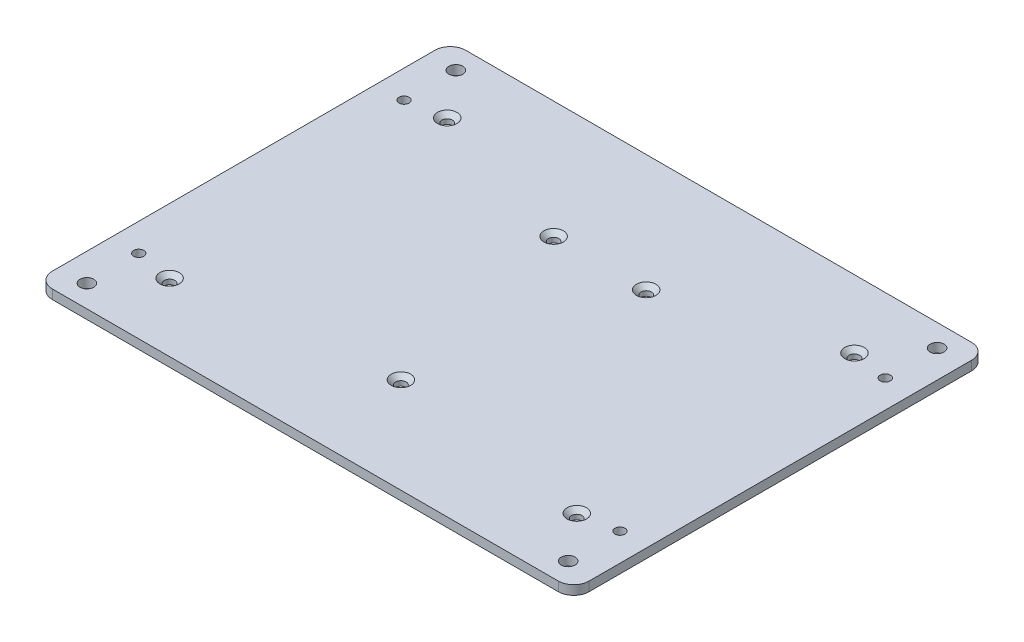
from build123d import *

# Parameters (mm, degrees)
SKETCH1_W                                    = 174
SKETCH1_H                                    = 134
BOSS_EXTRUDE1_DEPTH                          = 3
ASSEM71_D                                    = 3.3
FILLET1_R                                    = 5
CSK_FOR_M3_COUNTERSUNK_FLAT_HEAD_SCR_2_COUNT = 2
CSK_FOR_M3_COUNTERSUNK_FLAT_HEAD_SCR_2_PITCH = 132
CSK_FOR_M3_COUNTERSUNK_FLAT_HEAD_SCR_3_COUNT = 2
CSK_FOR_M3_COUNTERSUNK_FLAT_HEAD_SCR_3_PITCH = 90
CSK_FOR_M3_COUNTERSUNK_FLAT_HEAD_SCR_4_COUNT = 2
CSK_FOR_M3_COUNTERSUNK_FLAT_HEAD_SCR_4_PITCH = 159.762323468
CSK_FOR_M3_COUNTERSUNK_FLAT_HEAD_SCR_5_COUNT = 2
CSK_FOR_M3_COUNTERSUNK_FLAT_HEAD_SCR_5_PITCH = 66.597672632
CSK_FOR_M3_COUNTERSUNK_FLAT_HEAD_SCR_6_COUNT = 2
CSK_FOR_M3_COUNTERSUNK_FLAT_HEAD_SCR_6_PITCH = 66.822526142
M4_CLEARANCE_HOLE1_D                         = 4.5


with BuildPart() as part:
    # Sketch1 → Boss-Extrude1 (new body)
    with BuildSketch(Plane(origin=(0, 0, 0), x_dir=(1, 0, 0), z_dir=(0, 1, 0))):
        Rectangle(SKETCH1_W, SKETCH1_H)
    extrude(amount=BOSS_EXTRUDE1_DEPTH)

    # Assem71 (through all)
    with Locations(Plane(origin=(0, 3, 0), x_dir=(1, 0, 0), z_dir=(0, 1, 0))):
        with Locations((-77.999137931, 42.999137931), (77.999137931, 42.999137931), (77.999137931, -42.999137931), (-77.999137931, -42.999137931), (-77.999137931, 59.799137931), (-77.999137931, -59.799137931), (77.999137931, 59.799137931), (77.999137931, -59.799137931)):
            Hole(ASSEM71_D / 2)

    # Fillet1
    fillet1_edges = [part.edges().sort_by_distance(p)[0] for p in [
        (-87, 1.5, -67),
        (87, 1.5, -67),
        (87, 1.5, 67),
        (-87, 1.5, 67),
    ]]
    fillet(fillet1_edges, radius=FILLET1_R)

    # Sketch6 → CSK for M3 Countersunk Flat Head Screw1 (revolve, cut)
    with BuildSketch(Plane(origin=(-66, 3, -45), x_dir=(0, 0, 1), z_dir=(1, 0, 0))):
        Polygon((0, 0), (0, 3), (1.7, 3), (1.7, 1.45), (3.15, 0), align=None)
    csk_for_m3_countersunk_flat_head_screw1 = revolve(axis=Axis((-66, 9.35, -45), (0, -1, 0)), mode=Mode.SUBTRACT)

    # CSK for M3 Countersunk Flat Head Scr 2: CSK for M3 Countersunk Flat Head Screw1 ×2
    with Locations(*[(i * CSK_FOR_M3_COUNTERSUNK_FLAT_HEAD_SCR_2_PITCH, 0, 0) for i in range(1, CSK_FOR_M3_COUNTERSUNK_FLAT_HEAD_SCR_2_COUNT)]):
        add(csk_for_m3_countersunk_flat_head_screw1, mode=Mode.SUBTRACT)

    # CSK for M3 Countersunk Flat Head Scr 3: CSK for M3 Countersunk Flat Head Screw1 ×2
    with Locations(*[(0, 0, i * CSK_FOR_M3_COUNTERSUNK_FLAT_HEAD_SCR_3_PITCH) for i in range(1, CSK_FOR_M3_COUNTERSUNK_FLAT_HEAD_SCR_3_COUNT)]):
        add(csk_for_m3_countersunk_flat_head_screw1, mode=Mode.SUBTRACT)

    # CSK for M3 Countersunk Flat Head Scr 4: CSK for M3 Countersunk Flat Head Screw1 ×2
    with Locations(*[Vector(0.826227343, 0, 0.563336825) * (i * CSK_FOR_M3_COUNTERSUNK_FLAT_HEAD_SCR_4_PITCH) for i in range(1, CSK_FOR_M3_COUNTERSUNK_FLAT_HEAD_SCR_4_COUNT)]):
        add(csk_for_m3_countersunk_flat_head_screw1, mode=Mode.SUBTRACT)

    # Sketch8 → CSK for M3 Countersunk Flat Head Screw2 (revolve, cut)
    with BuildSketch(Plane(origin=(0, 3, 36), x_dir=(0, 0, 1), z_dir=(1, 0, 0))):
        Polygon((0, 0), (0, 3), (1.7, 3), (1.7, 1.45), (3.15, 0), align=None)
    csk_for_m3_countersunk_flat_head_screw2 = revolve(axis=Axis((0, 9.35, 36), (0, -1, 0)), mode=Mode.SUBTRACT)

    # CSK for M3 Countersunk Flat Head Scr 5: CSK for M3 Countersunk Flat Head Screw2 ×2
    with Locations(*[Vector(0.217725326, 0, -0.976010083) * (i * CSK_FOR_M3_COUNTERSUNK_FLAT_HEAD_SCR_5_PITCH) for i in range(1, CSK_FOR_M3_COUNTERSUNK_FLAT_HEAD_SCR_5_COUNT)]):
        add(csk_for_m3_countersunk_flat_head_screw2, mode=Mode.SUBTRACT)

    # CSK for M3 Countersunk Flat Head Scr 6: CSK for M3 Countersunk Flat Head Screw2 ×2
    with Locations(*[Vector(-0.231957708, 0, -0.972725872) * (i * CSK_FOR_M3_COUNTERSUNK_FLAT_HEAD_SCR_6_PITCH) for i in range(1, CSK_FOR_M3_COUNTERSUNK_FLAT_HEAD_SCR_6_COUNT)]):
        add(csk_for_m3_countersunk_flat_head_screw2, mode=Mode.SUBTRACT)

    # M4 Clearance Hole1 (through all)
    with Locations(Plane.XZ):
        with Locations((-77.999137931, -59.799137931), (77.999137931, -59.799137931), (77.999137931, 59.799137931), (-77.999137931, 59.799137931)):
            Hole(M4_CLEARANCE_HOLE1_D / 2)


solid = part.part
